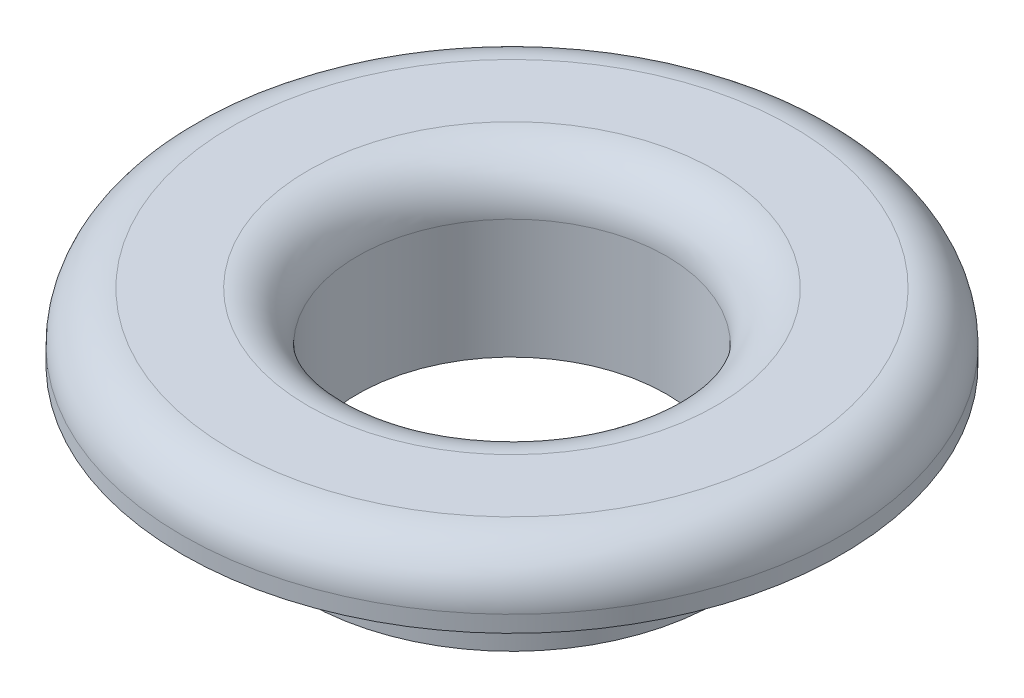
from build123d import *

# Parameters (mm, degrees)
SKETCH1_R           = 3.175
SKETCH1_R_2         = 2.38125
BOSS_EXTRUDE1_DEPTH = 1.5875
SKETCH2_R           = 5.08
SKETCH2_R_2         = 2.38125
BOSS_EXTRUDE2_DEPTH = 1.016
FILLET1_R           = 0.762


with BuildPart() as part:
    # Sketch1 → Boss-Extrude1 (new body)
    with BuildSketch(Plane(origin=(0, 0, 0), x_dir=(1, 0, 0), z_dir=(0, 1, 0))):
        Circle(SKETCH1_R)
        Circle(SKETCH1_R_2, mode=Mode.SUBTRACT)
    extrude(amount=BOSS_EXTRUDE1_DEPTH)

    # Sketch2 → Boss-Extrude2 (add)
    with BuildSketch(Plane(origin=(0, 1.5875, 0), x_dir=(1, 0, 0), z_dir=(0, 1, 0))):
        Circle(SKETCH2_R)
        Circle(SKETCH2_R_2, mode=Mode.SUBTRACT)
    extrude(amount=BOSS_EXTRUDE2_DEPTH)

    # Fillet1
    fillet1_edges = [part.edges().sort_by_distance(p)[0] for p in [
        (-2.38125, 2.6035, 0),
        (-5.08, 2.6035, 0),
    ]]
    fillet(fillet1_edges, radius=FILLET1_R)


solid = part.part
